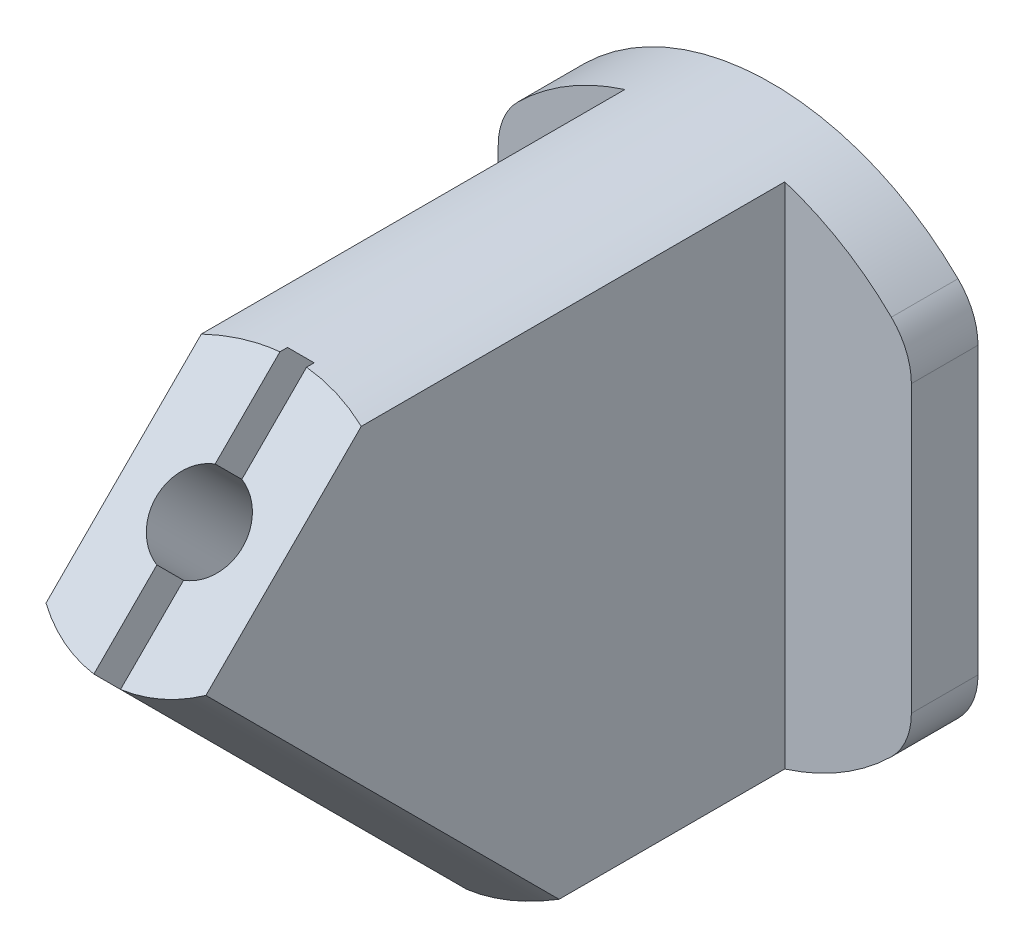
from build123d import *

# Parameters (mm, degrees)
BOSS_EXTRUDE1_DEPTH     = 50
CUT_EXTRUDE2_DEPTH      = 21
CUT_EXTRUDE2_DEPTH_BACK = 21
CUT_EXTRUDE3_DEPTH      = 10.5
CUT_EXTRUDE3_DEPTH_BACK = 22.5
CUT_EXTRUDE4_DEPTH      = 54.639610307


with BuildPart() as part:
    # Sketch1 → Boss-Extrude1 (new body)
    with BuildSketch(Plane.XY):
        with BuildLine():
            Line((-15.5, 10.712142643), (-15.5, -10.712142643))
            ThreePointArc((-15.5, -10.712142643), (-15.109772229, -12.648634316), (-14, -14.282856857))
            ThreePointArc((-14, -14.282856857), (0, -20), (14, -14.282856857))
            ThreePointArc((14, -14.282856857), (15.109772229, -12.648634316), (15.5, -10.712142643))
            Line((15.5, -10.712142643), (15.5, 10.712142643))
            ThreePointArc((15.5, 10.712142643), (15.109772229, 12.648634316), (14, 14.282856857))
            ThreePointArc((14, 14.282856857), (0, 20), (-14, 14.282856857))
            ThreePointArc((-14, 14.282856857), (-15.109772229, 12.648634316), (-15.5, 10.712142643))
        make_face()
    extrude(amount=BOSS_EXTRUDE1_DEPTH)

    # Sketch3 → Cut-Extrude2 (cut, two sides)
    with BuildSketch(Plane(origin=(0, 0, 0), x_dir=(1, 0, 0), z_dir=(0, 1, 0))) as cut_extrude2_sk:
        Polygon((-142.514750581, -5), (-18.067603989, -5), (-6, -5), (-6, -53.756778028), (6, -53.756778028), (6, -5), (19.848795464, -5), (144.295942056, -5), (144.295942056, -253.894293184), (-142.514750581, -253.894293184), align=None)
    extrude(amount=CUT_EXTRUDE2_DEPTH, mode=Mode.SUBTRACT)
    extrude(cut_extrude2_sk.sketch, amount=-CUT_EXTRUDE2_DEPTH_BACK, mode=Mode.SUBTRACT)

    # Sketch4 → Cut-Extrude3 (cut, two sides)
    with BuildSketch(Plane.ZY.offset(6)) as cut_extrude3_sk:
        Polygon((143.928068638, -88.070204261), (54.263494486, 1.594369891), (31.585867619, 24.271996758), (-58.078706533, 113.93657091), (121.250441771, 293.265719213), (323.257216942, 91.258944042), align=None)
    extrude(amount=CUT_EXTRUDE3_DEPTH, mode=Mode.SUBTRACT)
    extrude(cut_extrude3_sk.sketch, amount=-CUT_EXTRUDE3_DEPTH_BACK, mode=Mode.SUBTRACT)

    # Sketch5 → Cut-Extrude4 (cut, through all)
    with BuildSketch(Plane(origin=(0, 27.928932188, 27.928932188), x_dir=(1, 0, 0), z_dir=(0, 0.707106781, 0.707106781))):
        with BuildLine():
            Line((-7.514532889, -27.552153908), (-7.514532889, -51.5106924))
            Line((-7.514532889, -51.5106924), (9.293928827, -51.5106924))
            Line((9.293928827, -51.5106924), (9.293928827, -24.418415532))
            ThreePointArc((9.293928827, -24.418415532), (6.107254228, -28.917224685), (1, -30.993310676))
            Line((1, -30.993310676), (1, -24.305532655))
            ThreePointArc((1, -24.305532655), (3.25, -21.213203436), (1, -18.120874216))
            Line((1, -18.120874216), (1, -10.845979058))
            Line((1, -10.845979058), (-1, -10.845979058))
            Line((-1, -10.845979058), (-1, -18.120874216))
            ThreePointArc((-1, -18.120874216), (-3.25, -21.213203436), (-1, -24.305532655))
            Line((-1, -24.305532655), (-1, -30.993310676))
            ThreePointArc((-1, -30.993310676), (-4.591808745, -29.906062003), (-7.514532889, -27.552153908))
        make_face()
    extrude(amount=-CUT_EXTRUDE4_DEPTH, mode=Mode.SUBTRACT)


solid = part.part
